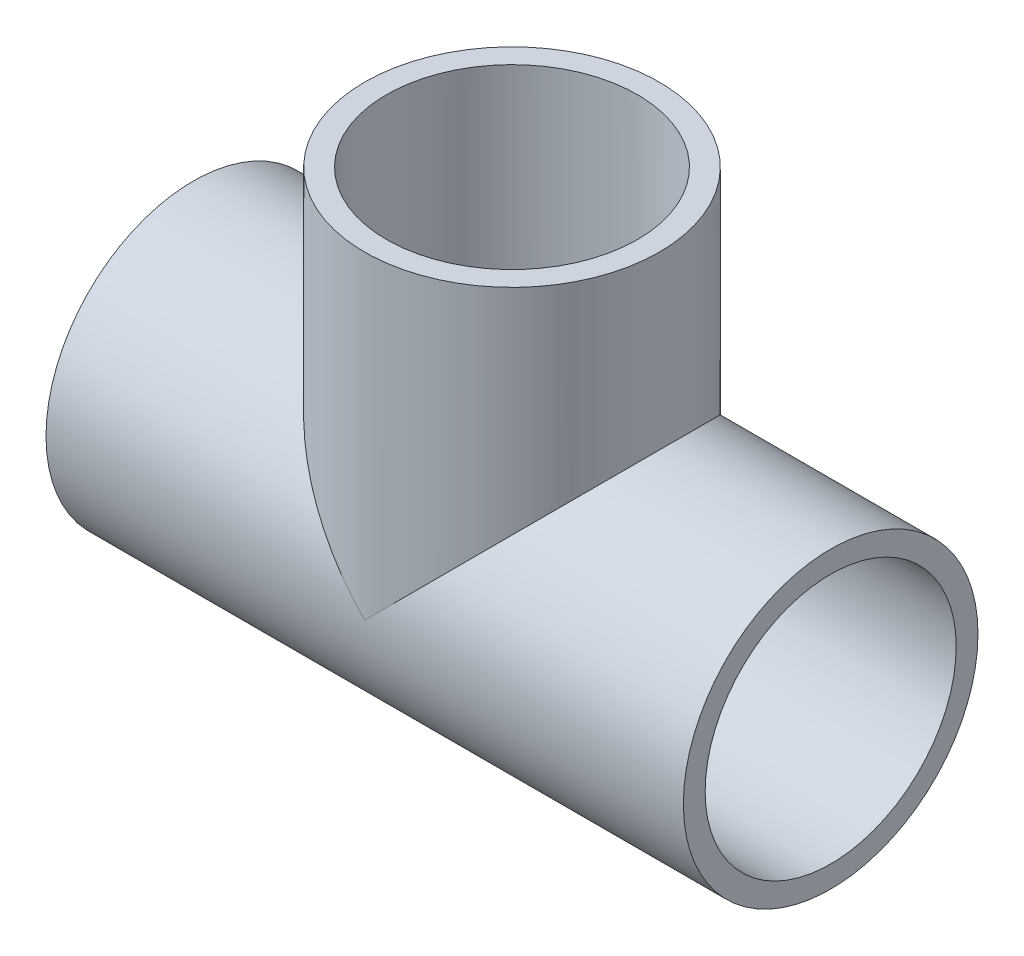
from build123d import *

# Parameters (mm, degrees)
SKETCH4_R           = 24.892
BOSS_EXTRUDE1_DEPTH = 44.45
SKETCH5_R           = 24.892
BOSS_EXTRUDE2_DEPTH = 22.225


with BuildPart() as part:
    # Sketch1 → Revolve1 (revolve)
    with BuildSketch(Plane.XY):
        Polygon((-53.848, -24.892), (-22.225, -24.892), (-22.225, -21.0185), (-53.848, -21.209), align=None)
        Polygon((53.848, -21.209), (22.225, -21.0185), (22.225, -24.892), (53.848, -24.892), align=None)
    revolve(axis=Axis((-53.848, 0, 0), (1, 0, 0)))



with BuildPart() as body_2:
    # Sketch2 → Revolve2 (revolve)
    with BuildSketch(Plane.XY):
        Polygon((21.209, 53.848), (21.0185, 22.225), (24.892, 22.225), (24.892, 53.848), align=None)
    revolve(axis=Axis((0, 0, 0), (0, 1, 0)))


with BuildPart() as part_1:
    add(part.part)

    add(body_2.part)  # Boss-Extrude1 merges body 2
    # Sketch4 → Boss-Extrude1 (add)
    with BuildSketch(Plane(origin=(-22.225, 0, 0), x_dir=(0, 0, -1), z_dir=(1, 0, 0))):
        Circle(SKETCH4_R)
    extrude(amount=BOSS_EXTRUDE1_DEPTH)

    # Sketch5 → Boss-Extrude2 (add)
    with BuildSketch(Plane.XZ.offset(-22.225)):
        Circle(SKETCH5_R)
    extrude(amount=BOSS_EXTRUDE2_DEPTH)

    # Sketch6 → Cut-Revolve1 (revolve, cut)
    with BuildSketch(Plane.XY):
        Polygon((-53.848, -21.209), (-22.225, -21.0185), (-22.225, -17.526), (22.225, -17.526), (22.225, -21.0185), (53.848, -21.209), (53.848, 0), (-53.848, 0), align=None)
    revolve(axis=Axis((53.848, 0, 0), (-1, 0, 0)), mode=Mode.SUBTRACT)

    # Sketch7 → Cut-Revolve2 (revolve, cut)
    with BuildSketch(Plane.XY):
        Polygon((21.209, 53.848), (21.0185, 22.225), (17.526, 22.225), (17.526, 0), (0, 0), (0, 53.848), align=None)
    revolve(axis=Axis((0, 0, 0), (0, 1, 0)), mode=Mode.SUBTRACT)


solid = part_1.part
